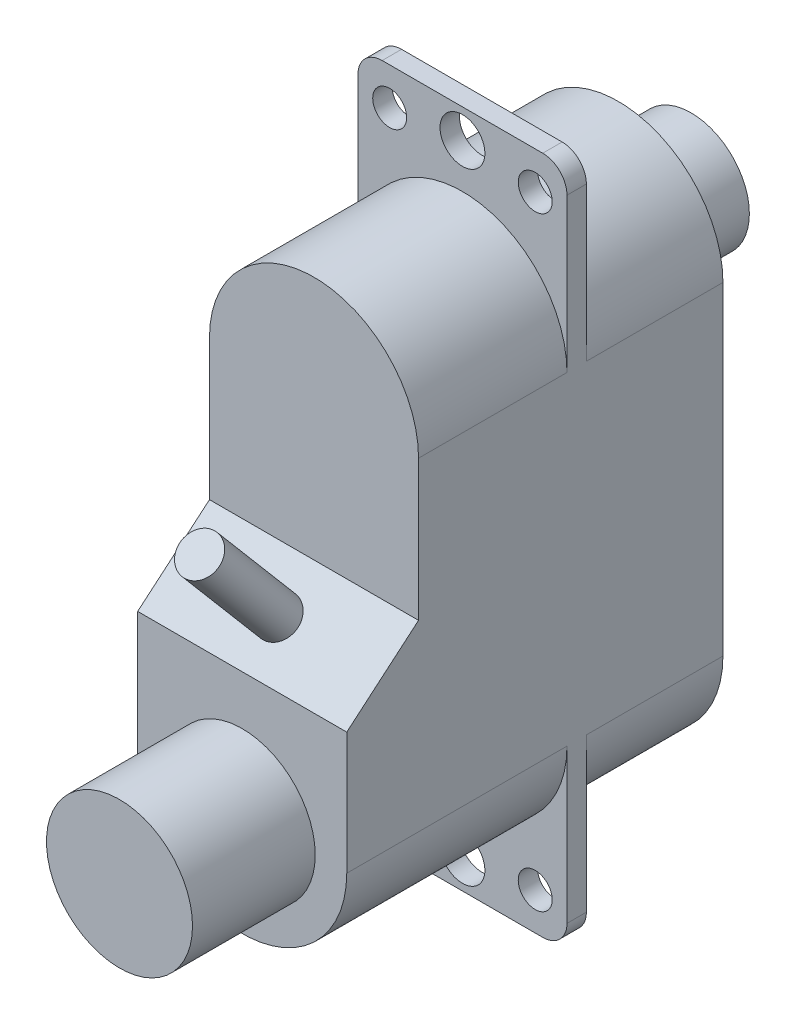
from build123d import *

# Parameters (mm, degrees)
SKETCH1_R               = 2.4
BOSS_EXTRUDE1_DEPTH     = 3
BOSS_EXTRUDE2_DEPTH     = 15.51
CUT_EXTRUDE1_DEPTH      = 26.936821316
CUT_EXTRUDE1_DEPTH_BACK = 26.936821316
SKETCH4_R               = 3.01
BOSS_EXTRUDE3_DEPTH     = 5.06
SKETCH5_R               = 0.925
SKETCH5_R_2             = 0.7
BOSS_EXTRUDE4_DEPTH     = 0.8
SKETCH6_R               = 0.823117729
BOSS_EXTRUDE5_DEPTH     = 5


with BuildPart() as part:
    # Sketch1 → Boss-Extrude1 (new body)
    with BuildSketch(Plane.XY):
        Circle(SKETCH1_R)
    extrude(amount=BOSS_EXTRUDE1_DEPTH)

    # Sketch2 → Boss-Extrude2 (add)
    with BuildSketch(Plane.XY.offset(3)):
        with BuildLine():
            Line((4.31, 0), (4.31, -13.34))
            ThreePointArc((4.31, -13.34), (0, -17.65), (-4.31, -13.34))
            Line((-4.31, -13.34), (-4.31, 0))
            ThreePointArc((-4.31, 0), (0, 4.31), (4.31, 0))
        make_face()
    extrude(amount=BOSS_EXTRUDE2_DEPTH)

    # Sketch3 → Cut-Extrude1 (cut, two sides: drawn at the far end of the back side and taken through both)
    with BuildSketch(Plane(origin=(0, 0, 0), x_dir=(0, 0, -1), z_dir=(1, 0, 0)).offset(-CUT_EXTRUDE1_DEPTH_BACK)):
        Polygon((-18.51, 4.31), (-15.55, 4.31), (-15.55, -5.79), (-18.51, -8.3), align=None)
    extrude(amount=CUT_EXTRUDE1_DEPTH + CUT_EXTRUDE1_DEPTH_BACK, mode=Mode.SUBTRACT)

    # Sketch4 → Boss-Extrude3 (add)
    with BuildSketch(Plane.XY.offset(18.51)):
        with Locations((0, -13.34)):
            Circle(SKETCH4_R)
    extrude(amount=BOSS_EXTRUDE3_DEPTH)

    # Sketch5 → Boss-Extrude4 (add)
    with BuildSketch(Plane(origin=(0, 0, 8.63), x_dir=(-1, 0, 0), z_dir=(0, 0, -1))):
        with BuildLine():
            Line((-3.31, 7.33), (3.31, 7.33))
            ThreePointArc((3.31, 7.33), (4.017106781, 7.037106781), (4.31, 6.33))
            Line((4.31, 6.33), (4.31, -19.67))
            ThreePointArc((4.31, -19.67), (4.017106781, -20.377106781), (3.31, -20.67))
            Line((3.31, -20.67), (-3.31, -20.67))
            ThreePointArc((-3.31, -20.67), (-4.017106781, -20.377106781), (-4.31, -19.67))
            Line((-4.31, -19.67), (-4.31, 6.33))
            ThreePointArc((-4.31, 6.33), (-4.017106781, 7.037106781), (-3.31, 7.33))
        make_face()
        with Locations((0, 6.13)):
            Circle(SKETCH5_R, mode=Mode.SUBTRACT)
        with Locations((3, 5.79076381)):
            Circle(SKETCH5_R_2, mode=Mode.SUBTRACT)
        with Locations((-3, 5.79076381)):
            Circle(SKETCH5_R_2, mode=Mode.SUBTRACT)
        with Locations((3, -19.13076381)):
            Circle(SKETCH5_R_2, mode=Mode.SUBTRACT)
        with Locations((0, -19.47)):
            Circle(SKETCH5_R, mode=Mode.SUBTRACT)
        with Locations((-3, -19.13076381)):
            Circle(SKETCH5_R_2, mode=Mode.SUBTRACT)
    extrude(amount=-BOSS_EXTRUDE4_DEPTH)

    # Sketch6 → Boss-Extrude5 (add)
    with BuildSketch(Plane(origin=(0, 4.302344091, 3.64827151), x_dir=(1, 0, 0), z_dir=(0, 0.7627017002465386, 0.6467504282495988))):
        with Locations((0, -17.550441075)):
            Circle(SKETCH6_R)
    extrude(amount=BOSS_EXTRUDE5_DEPTH)


solid = part.part
